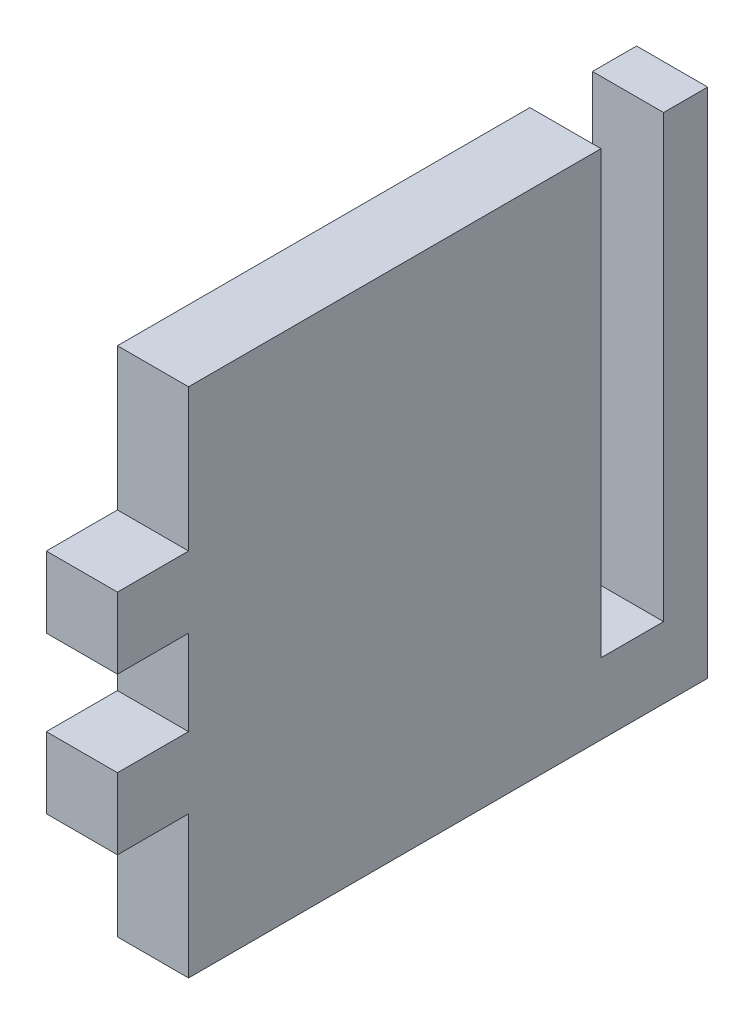
from build123d import *

# Parameters (mm, degrees)
SKETCH1_W           = 52.705
SKETCH1_H           = 45.72
BOSS_EXTRUDE1_DEPTH = 6.35
SKETCH2_W           = 6.35
SKETCH2_H           = 12.7
SKETCH2_H_2         = 7.62
SKETCH2_W_2         = 5.588
SKETCH2_H_3         = 39.37
CUT_EXTRUDE1_DEPTH  = 7.35


with BuildPart() as part:
    # Sketch1 → Boss-Extrude1 (new body)
    with BuildSketch(Plane(origin=(0, 0, 0), x_dir=(0, 0, -1), z_dir=(1, 0, 0))):
        with Locations((26.3525, 22.86)):
            Rectangle(SKETCH1_W, SKETCH1_H)
    extrude(amount=BOSS_EXTRUDE1_DEPTH)

    # Sketch2 → Cut-Extrude1 (cut, through all)
    with BuildSketch(Plane(origin=(6.35, 0, 0), x_dir=(0, 0, -1), z_dir=(1, 0, 0))):
        with Locations((3.175, 39.37)):
            Rectangle(SKETCH2_W, SKETCH2_H)
        with Locations((3.175, 6.35)):
            Rectangle(SKETCH2_W, SKETCH2_H)
        with Locations((3.175, 22.86)):
            Rectangle(SKETCH2_W, SKETCH2_H_2)
        with Locations((45.974, 26.035)):
            Rectangle(SKETCH2_W_2, SKETCH2_H_3)
    extrude(amount=-CUT_EXTRUDE1_DEPTH, mode=Mode.SUBTRACT)


solid = part.part
